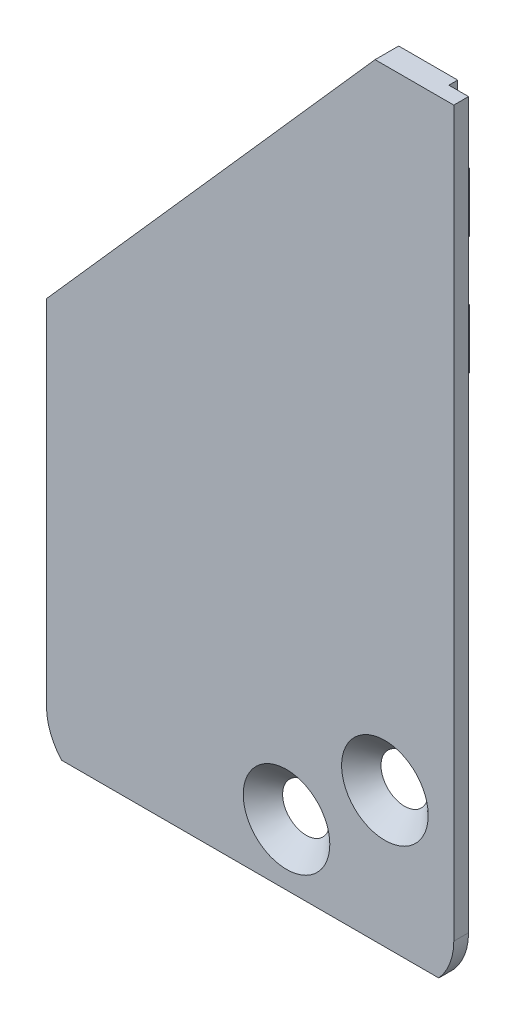
from build123d import *

# Parameters (mm, degrees)
BOSS_EXTRUDE1_DEPTH                             = 0.8
BOSS_EXTRUDE1_2_DEPTH                           = 0.8
BOSS_EXTRUDE3_DEPTH                             = 1
BOSS_EXTRUDE3_DEPTH_BACK                        = 0.2
FILLET1_R                                       = 2
CUT_EXTRUDE1_DEPTH                              = 0.2
BOSS_EXTRUDE4_DEPTH                             = 0.75
CSK_FOR_M2_FLAT_HEAD_MACHINE_SCREW1_D           = 2.4
CSK_FOR_M2_FLAT_HEAD_MACHINE_SCREW1_DEPTH       = 4
CSK_FOR_M2_FLAT_HEAD_MACHINE_SCREW1_CSINK_D     = 4.4
CSK_FOR_M2_FLAT_HEAD_MACHINE_SCREW1_CSINK_ANGLE = 90
CSK_FOR_M2_FLAT_HEAD_MACHINE_SCREW1_TIP         = 0.721032743


with BuildPart() as part:
    # Sketch1 → Boss-Extrude1 (new body)
    with BuildSketch(Plane.XY):
        with BuildLine():
            Line((11.255059848, 53.733600539), (13.255059848, 53.733600539))
            Line((13.255059848, 53.733600539), (13.255059848, 50.733600539))
            Line((13.255059848, 50.733600539), (11.255059848, 50.733600539))
            ThreePointArc((11.255059848, 50.733600539), (9.755059848, 52.233600539), (11.255059848, 53.733600539))
        make_face()
    extrude(amount=-BOSS_EXTRUDE1_DEPTH)



with BuildPart() as body_2:
    # Sketch1 → Boss-Extrude1 2 (new body)
    with BuildSketch(Plane.XY):
        with BuildLine():
            Line((11.255059848, 47.733600539), (13.255059848, 47.733600539))
            Line((13.255059848, 47.733600539), (13.255059848, 44.733600539))
            Line((13.255059848, 44.733600539), (11.255059848, 44.733600539))
            ThreePointArc((11.255059848, 44.733600539), (9.755059848, 46.233600539), (11.255059848, 47.733600539))
        make_face()
    extrude(amount=-BOSS_EXTRUDE1_2_DEPTH)


with BuildPart() as part_1:
    add(part.part)

    add(body_2.part)  # Boss-Extrude3 merges body 2
    # Sketch2 → Boss-Extrude3 (add, two sides)
    with BuildSketch(Plane.XY) as boss_extrude3_sk:
        Polygon((-5.444940152, 19.108600539), (13.255059848, 19.108600539), (13.255059848, 57.908600539), (10.255059848, 57.908600539), (-5.444940152, 40.168487545), align=None)
    extrude(amount=BOSS_EXTRUDE3_DEPTH)
    extrude(boss_extrude3_sk.sketch, amount=-BOSS_EXTRUDE3_DEPTH_BACK)

    # Fillet1
    fillet1_edges = [part_1.edges().sort_by_distance(p)[0] for p in [
        (-5.444940152, 19.108600539, 0.4),
        (13.255059848, 19.108600539, 0.4),
    ]]
    fillet(fillet1_edges, radius=FILLET1_R)

    # Sketch3 → Cut-Extrude1 (cut)
    with BuildSketch(Plane(origin=(0, 0, 0), x_dir=(-1, 0, 0), z_dir=(0, 0, -1))):
        Polygon((-13.255059848, 33.233600539), (-13.255059848, 19.108600539), (5.444940152, 19.108600539), (3.444940152, 20.619295727), align=None)
    extrude(amount=CUT_EXTRUDE1_DEPTH, mode=Mode.SUBTRACT)

    # Sketch4 → Boss-Extrude4 (add)
    with BuildSketch(Plane.XY.offset(1)):
        with BuildLine():
            Line((-6.444940152, 39.038544042), (-6.444940152, 21.108600539))
            ThreePointArc((-6.444940152, 21.108600539), (-6.247457228, 20.03813427), (-5.681008129, 19.108600539))
            Line((-5.681008129, 19.108600539), (13.491127826, 19.108600539))
            ThreePointArc((13.491127826, 19.108600539), (14.057576925, 20.03813427), (14.255059848, 21.108600539))
            Line((14.255059848, 21.108600539), (14.255059848, 57.908600539))
            Line((14.255059848, 57.908600539), (10.255059848, 57.908600539))
            Line((10.255059848, 57.908600539), (-6.444940152, 39.038544042))
        make_face()
    extrude(amount=-BOSS_EXTRUDE4_DEPTH)

    # CSK for M2 Flat Head Machine Screw1
    with Locations(Plane(origin=(-1.094940152, -30.37062024, 1), x_dir=(1, 0, 0), z_dir=(0, 0, 1))):
        with Locations((11.85, 56.367589763), (6.85, 52.590851795)):
            CounterSinkHole(CSK_FOR_M2_FLAT_HEAD_MACHINE_SCREW1_D / 2, CSK_FOR_M2_FLAT_HEAD_MACHINE_SCREW1_CSINK_D / 2, depth=CSK_FOR_M2_FLAT_HEAD_MACHINE_SCREW1_DEPTH, counter_sink_angle=CSK_FOR_M2_FLAT_HEAD_MACHINE_SCREW1_CSINK_ANGLE)
            with Locations((0, 0, -(CSK_FOR_M2_FLAT_HEAD_MACHINE_SCREW1_DEPTH + CSK_FOR_M2_FLAT_HEAD_MACHINE_SCREW1_TIP / 2))):  # 118° drill point
                Cone(0, CSK_FOR_M2_FLAT_HEAD_MACHINE_SCREW1_D / 2, CSK_FOR_M2_FLAT_HEAD_MACHINE_SCREW1_TIP, mode=Mode.SUBTRACT)


solid = part_1.part
